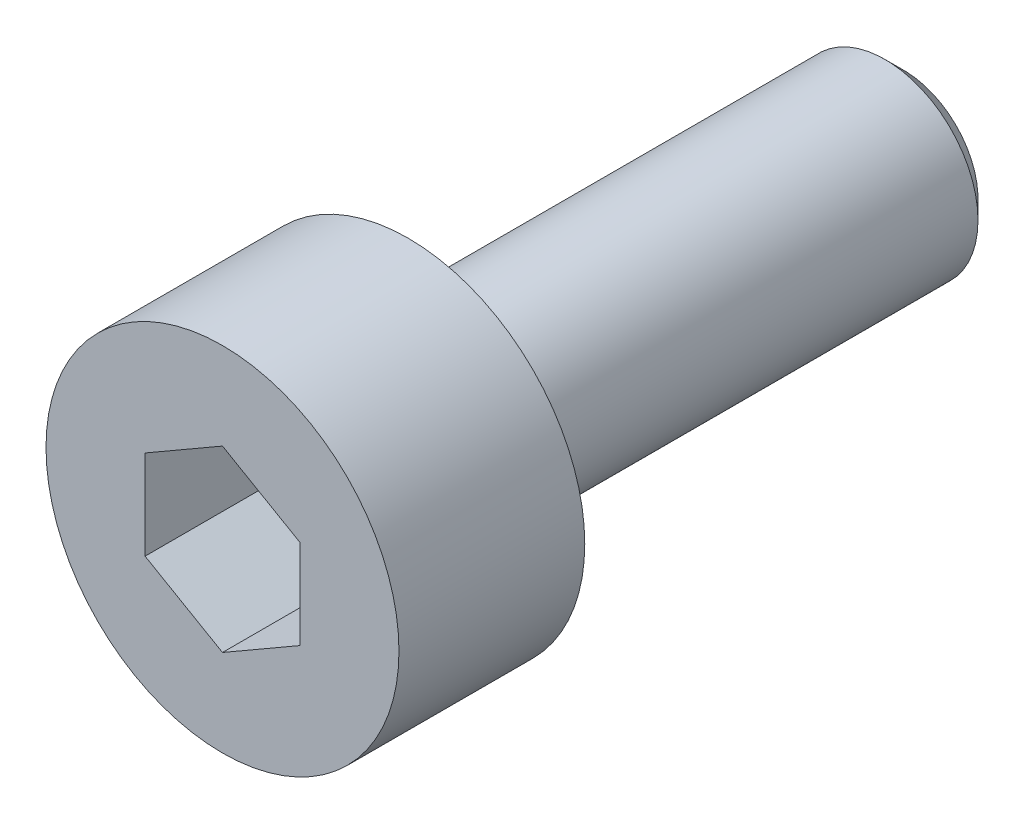
from build123d import *

# Parameters (mm, degrees)
SKETCH1_R           = 2.85
BOSS_EXTRUDE1_DEPTH = 3
SKETCH2_R           = 1.5
BOSS_EXTRUDE2_DEPTH = 8
CHAMFER1_SIZE       = 0.3
CUT_EXTRUDE1_DEPTH  = 2


with BuildPart() as part:
    # Sketch1 → Boss-Extrude1 (new body)
    with BuildSketch(Plane.XY):
        Circle(SKETCH1_R)
    extrude(amount=BOSS_EXTRUDE1_DEPTH)

    # Sketch2 → Boss-Extrude2 (add)
    with BuildSketch(Plane(origin=(0, 0, 0), x_dir=(-1, 0, 0), z_dir=(0, 0, -1))):
        Circle(SKETCH2_R)
    extrude(amount=BOSS_EXTRUDE2_DEPTH)

    # Chamfer1
    chamfer1_edges = [part.edges().sort_by_distance(p)[0] for p in [
        (1.5, 0, -8),
    ]]
    chamfer(chamfer1_edges, length=CHAMFER1_SIZE)

    # Sketch3 → Cut-Extrude1 (cut)
    with BuildSketch(Plane.XY.offset(3)):
        Polygon((0, 1.443375673), (-1.25, 0.721687836), (-1.25, -0.721687836), (0, -1.443375673), (1.25, -0.721687836), (1.25, 0.721687836), align=None)
    extrude(amount=-CUT_EXTRUDE1_DEPTH, mode=Mode.SUBTRACT)


solid = part.part
